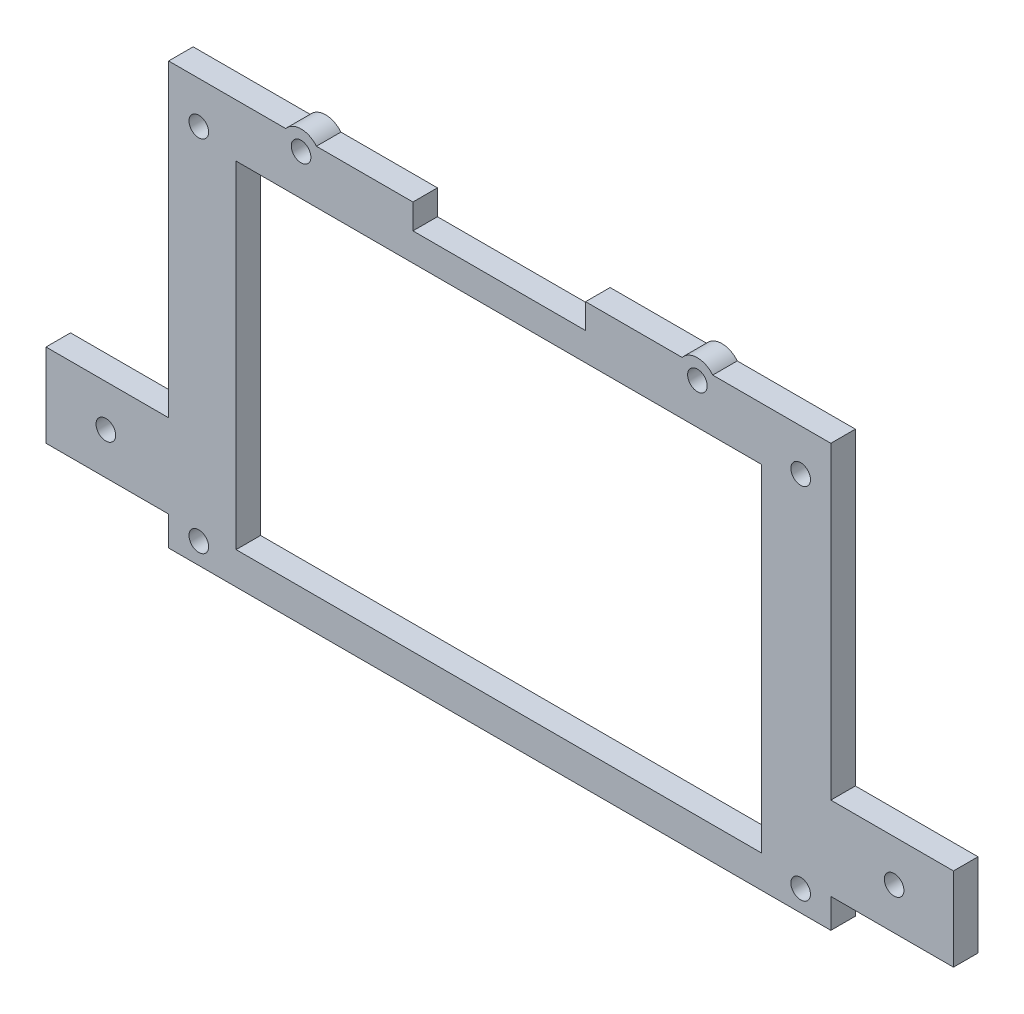
from build123d import *

# Parameters (mm, degrees)
SKETCH1_W           = 135
SKETCH1_H           = 86
BOSS_EXTRUDE1_DEPTH = 5
SKETCH2_W           = 35.2
SKETCH2_H           = 5.1
CUT_EXTRUDE1_DEPTH  = 5
SKETCH3_W           = 25
SKETCH3_H           = 17
BOSS_EXTRUDE2_DEPTH = 5
SKETCH4_W           = 107.1
SKETCH4_H           = 68.6
CUT_EXTRUDE2_DEPTH  = 5
SKETCH5_R           = 2
CUT_EXTRUDE3_DEPTH  = 10
SKETCH6_R           = 4
SKETCH6_R_2         = 2
BOSS_EXTRUDE3_DEPTH = 5
SKETCH7_R           = 2
CUT_EXTRUDE4_DEPTH  = 5


with BuildPart() as part:
    # Sketch1 → Boss-Extrude1 (new body)
    with BuildSketch(Plane.XY):
        Rectangle(SKETCH1_W, SKETCH1_H)
    extrude(amount=BOSS_EXTRUDE1_DEPTH)

    # Sketch2 → Cut-Extrude1 (cut)
    with BuildSketch(Plane(origin=(0, 0, 0), x_dir=(-1, 0, 0), z_dir=(0, 0, -1))):
        with Locations((0.1, 40.45)):
            Rectangle(SKETCH2_W, SKETCH2_H)
    extrude(amount=-CUT_EXTRUDE1_DEPTH, mode=Mode.SUBTRACT)

    # Sketch3 → Boss-Extrude2 (add)
    with BuildSketch(Plane(origin=(0, 0, 0), x_dir=(-1, 0, 0), z_dir=(0, 0, -1))):
        with Locations((80, -28.5)):
            Rectangle(SKETCH3_W, SKETCH3_H)
        with Locations((-80, -28.5)):
            Rectangle(SKETCH3_W, SKETCH3_H)
    extrude(amount=-BOSS_EXTRUDE2_DEPTH)

    # Sketch4 → Cut-Extrude2 (cut)
    with BuildSketch(Plane(origin=(0, 0, 0), x_dir=(-1, 0, 0), z_dir=(0, 0, -1))):
        with Locations((0.2, -2.1)):
            Rectangle(SKETCH4_W, SKETCH4_H)
    extrude(amount=-CUT_EXTRUDE2_DEPTH, mode=Mode.SUBTRACT)

    # Sketch5 → Cut-Extrude3 (cut)
    with BuildSketch(Plane(origin=(0, 0, 0), x_dir=(-1, 0, 0), z_dir=(0, 0, -1))):
        with Locations((-40.3, 40.5)):
            Circle(SKETCH5_R)
        with Locations((-80.4, -28.5)):
            Circle(SKETCH5_R)
        with Locations((80.3, -28.5)):
            Circle(SKETCH5_R)
        with Locations((40.5, 40.5)):
            Circle(SKETCH5_R)
    extrude(amount=-CUT_EXTRUDE3_DEPTH, mode=Mode.SUBTRACT)

    # Sketch6 → Boss-Extrude3 (add)
    with BuildSketch(Plane(origin=(0, 0, 0), x_dir=(-1, 0, 0), z_dir=(0, 0, -1))):
        with Locations((40.5, 40.5)):
            Circle(SKETCH6_R)
        with Locations((40.5, 40.5)):
            Circle(SKETCH6_R_2, mode=Mode.SUBTRACT)
        with Locations((-40.3, 40.5)):
            Circle(SKETCH6_R)
        with Locations((-40.3, 40.5)):
            Circle(SKETCH6_R_2, mode=Mode.SUBTRACT)
    extrude(amount=-BOSS_EXTRUDE3_DEPTH)

    # Sketch7 → Cut-Extrude4 (cut)
    with BuildSketch(Plane(origin=(0, 0, 0), x_dir=(-1, 0, 0), z_dir=(0, 0, -1))):
        with Locations((61.35, -38.7)):
            Circle(SKETCH7_R)
        with Locations((-61.35, -38.7)):
            Circle(SKETCH7_R)
        with Locations((-61.35, 34.5)):
            Circle(SKETCH7_R)
        with Locations((61.35, 34.5)):
            Circle(SKETCH7_R)
    extrude(amount=-CUT_EXTRUDE4_DEPTH, mode=Mode.SUBTRACT)


solid = part.part
